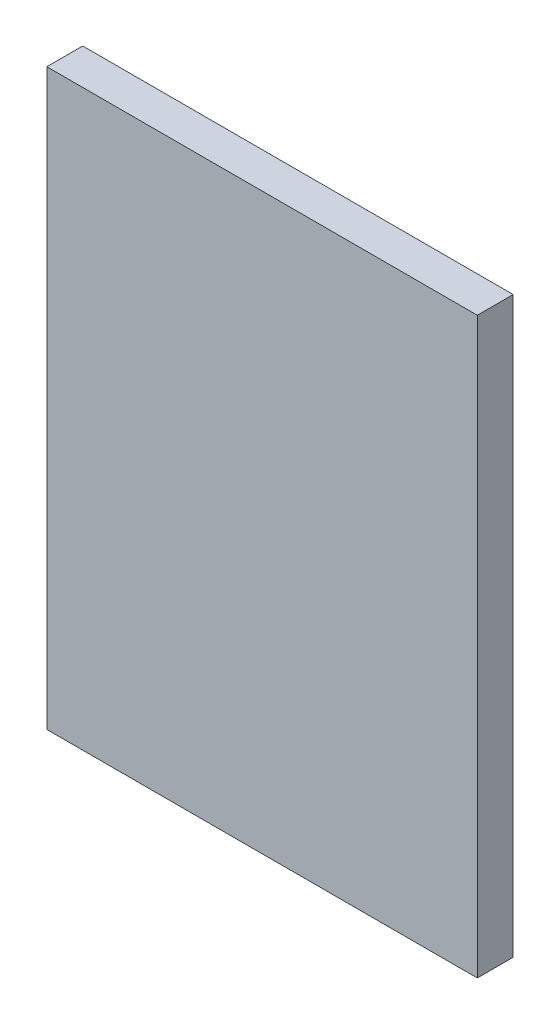
from build123d import *

# Parameters (mm, degrees)
SKETCH2_W           = 38.1
SKETCH2_H           = 50.8
BOSS_EXTRUDE1_DEPTH = 3.175


with BuildPart() as part:
    # Sketch2 → Boss-Extrude1 (new body)
    with BuildSketch(Plane.XY):
        Rectangle(SKETCH2_W, SKETCH2_H)
    extrude(amount=BOSS_EXTRUDE1_DEPTH)


solid = part.part
